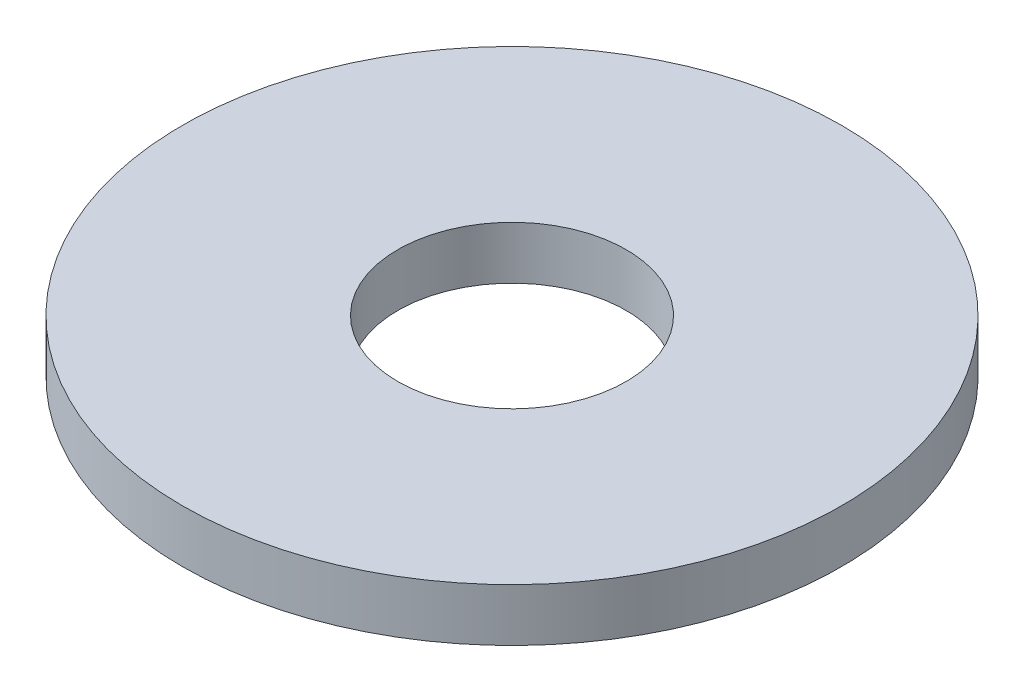
from build123d import *

# Parameters (mm, degrees)
SKETCH_1_R      = 7.5
SKETCH_1_R_2    = 2.6
EXTRUDE_1_DEPTH = 1.2


with BuildPart() as part:
    # 草图1 → 凸台-拉伸1 (new body)
    with BuildSketch(Plane(origin=(0, 0, 0), x_dir=(1, 0, 0), z_dir=(0, 1, 0))):
        Circle(SKETCH_1_R)
        Circle(SKETCH_1_R_2, mode=Mode.SUBTRACT)
    extrude(amount=EXTRUDE_1_DEPTH)


solid = part.part
